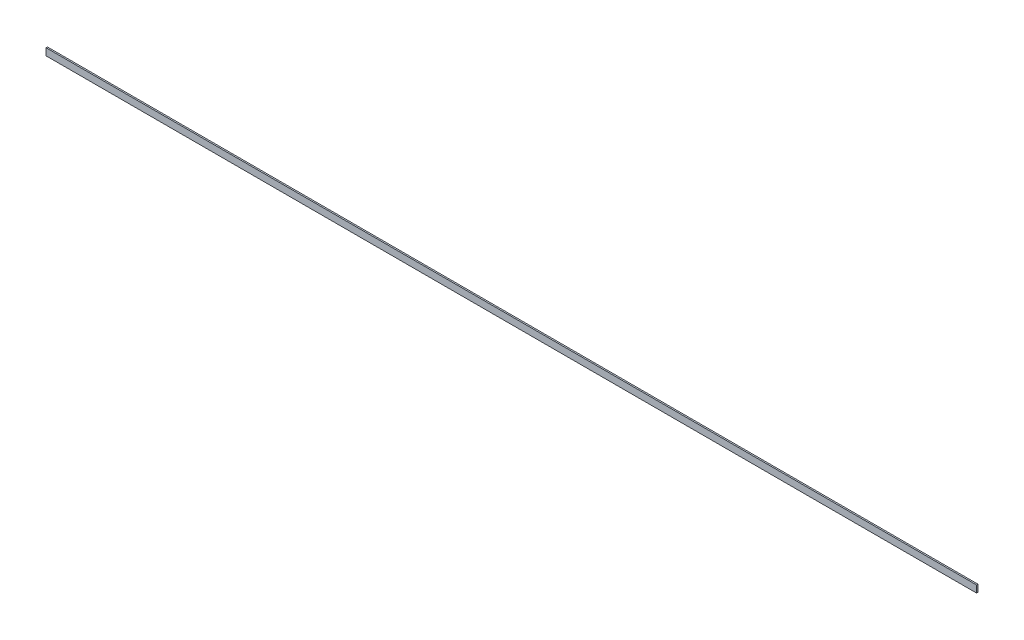
from build123d import *

# Parameters (mm, degrees)
SKETCH_1_W      = 4
SKETCH_1_H      = 20
EXTRUDE_1_DEPTH = 2650


with BuildPart() as part:
    # Эскиз1 → Бобышка-Вытянуть1 (new body)
    with BuildSketch(Plane(origin=(0, 0, 0), x_dir=(0, 0, -1), z_dir=(1, 0, 0))):
        with Locations((2, 10)):
            Rectangle(SKETCH_1_W, SKETCH_1_H)
    extrude(amount=EXTRUDE_1_DEPTH)


solid = part.part
